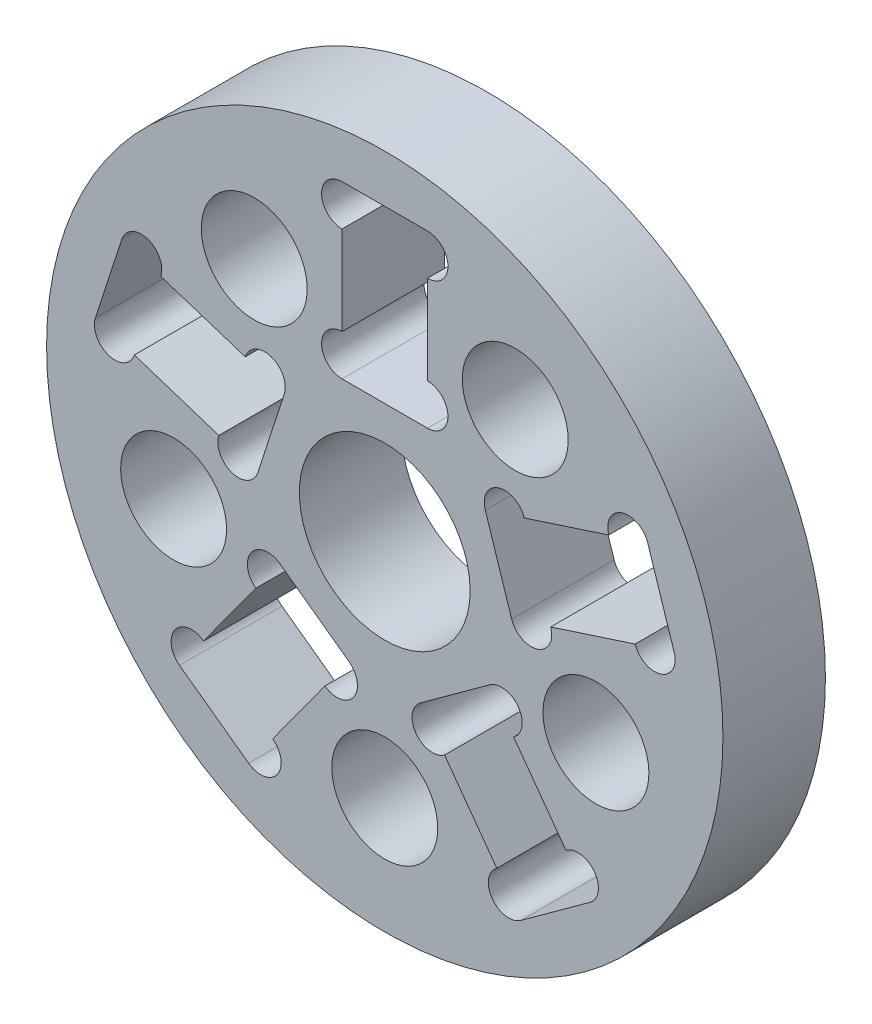
from build123d import *

# Parameters (mm, degrees)
SKETCH_1_R               = 9.9
EXTRUDE_1_DEPTH          = 1.5
SKETCH_2_R               = 1.55
SKETCH_2_W               = 2.5
SKETCH_2_H               = 5
CUT_EXTRUDE_1_DEPTH      = 4
PATTERN_CIRCULAR_1_COUNT = 5
SKETCH_3_R               = 0.6
CUT_EXTRUDE_2_DEPTH      = 4
PATTERN_CIRCULAR_2_COUNT = 5
SKETCH_4_R               = 2.5
CUT_EXTRUDE_3_DEPTH      = 4


with BuildPart() as part:
    # 草图1 → 凸台-拉伸1 (new body, symmetric)
    with BuildSketch(Plane.XY):
        Circle(SKETCH_1_R)
    extrude(amount=EXTRUDE_1_DEPTH, both=True)

    # 草图2 → 切除-拉伸1 (cut, through all)
    with BuildSketch(Plane.XY.offset(1.5)):
        with Locations((0, -6.5)):
            Circle(SKETCH_2_R)
        with Locations((0, 6)):
            Rectangle(SKETCH_2_W, SKETCH_2_H)
    cut_extrude_1 = extrude(amount=-CUT_EXTRUDE_1_DEPTH, mode=Mode.SUBTRACT)

    # 阵列(圆周)1: 切除-拉伸1 ×5 about axis
    pattern_circular_1_axis = Axis((0, 0, 0), (0, 0, 1))
    for i in range(1, PATTERN_CIRCULAR_1_COUNT):
        add(cut_extrude_1.rotate(pattern_circular_1_axis, i * 360 / PATTERN_CIRCULAR_1_COUNT), mode=Mode.SUBTRACT)

    # 草图3 → 切除-拉伸2 (cut, through all)
    with BuildSketch(Plane.XY.offset(1.5)):
        with Locations((1.25, 7.9)):
            Circle(SKETCH_3_R)
        with Locations((-1.25, 7.9)):
            Circle(SKETCH_3_R)
        with Locations((-1.25, 4.1)):
            Circle(SKETCH_3_R)
        with Locations((1.25, 4.1)):
            Circle(SKETCH_3_R)
    cut_extrude_2 = extrude(amount=-CUT_EXTRUDE_2_DEPTH, mode=Mode.SUBTRACT)

    # 阵列(圆周)2: 切除-拉伸2 ×5 about axis
    pattern_circular_2_axis = Axis((0, 0, 0), (0, 0, 1))
    for i in range(1, PATTERN_CIRCULAR_2_COUNT):
        add(cut_extrude_2.rotate(pattern_circular_2_axis, i * 360 / PATTERN_CIRCULAR_2_COUNT), mode=Mode.SUBTRACT)

    # 草图4 → 切除-拉伸3 (cut, through all)
    with BuildSketch(Plane.XY.offset(1.5)):
        Circle(SKETCH_4_R)
    extrude(amount=-CUT_EXTRUDE_3_DEPTH, mode=Mode.SUBTRACT)


solid = part.part
